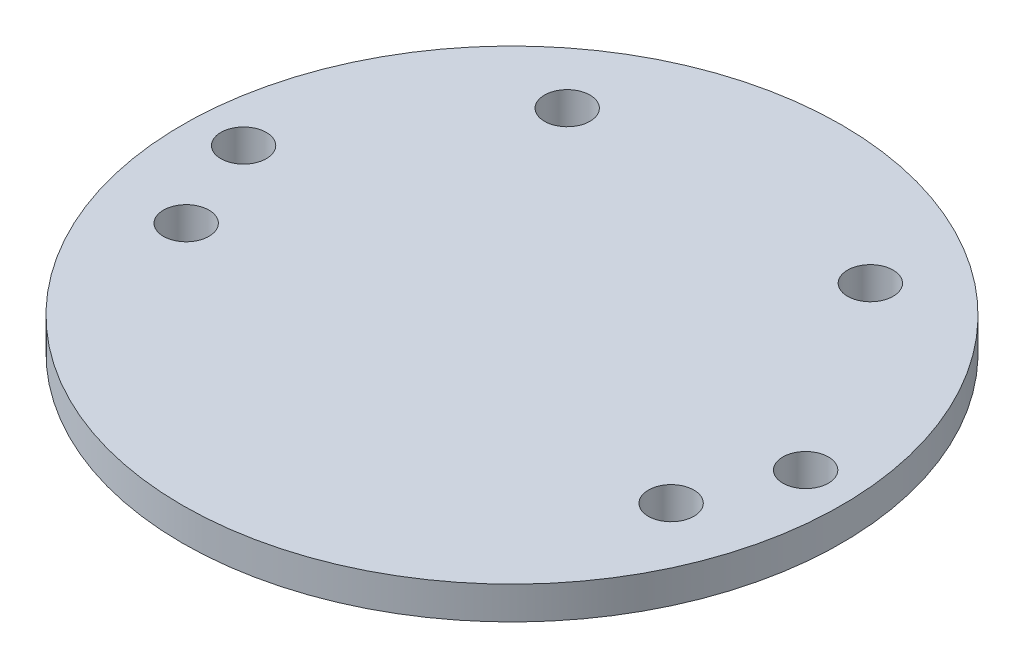
from build123d import *

# Parameters (mm, degrees)
SKETCH1_R           = 50.292
SKETCH1_R_2         = 3.475
BOSS_EXTRUDE1_DEPTH = 5


with BuildPart() as part:
    # Sketch1 → Boss-Extrude1 (new body)
    with BuildSketch(Plane(origin=(0, 0, 0), x_dir=(1, 0, 0), z_dir=(0, 1, 0))):
        Circle(SKETCH1_R)
        with Locations((42.886820356, 1.924977859)):
            Circle(SKETCH1_R_2, mode=Mode.SUBTRACT)
        with Locations((-42.886820356, 1.924977859)):
            Circle(SKETCH1_R_2, mode=Mode.SUBTRACT)
        with Locations((-37.000474826, -12.718618748)):
            Circle(SKETCH1_R_2, mode=Mode.SUBTRACT)
        with Locations((-23.129730363, 31.556520301)):
            Circle(SKETCH1_R_2, mode=Mode.SUBTRACT)
        with Locations((37.000474826, -12.718618748)):
            Circle(SKETCH1_R_2, mode=Mode.SUBTRACT)
        with Locations((23.129730363, 31.556520301)):
            Circle(SKETCH1_R_2, mode=Mode.SUBTRACT)
    extrude(amount=BOSS_EXTRUDE1_DEPTH)


solid = part.part
